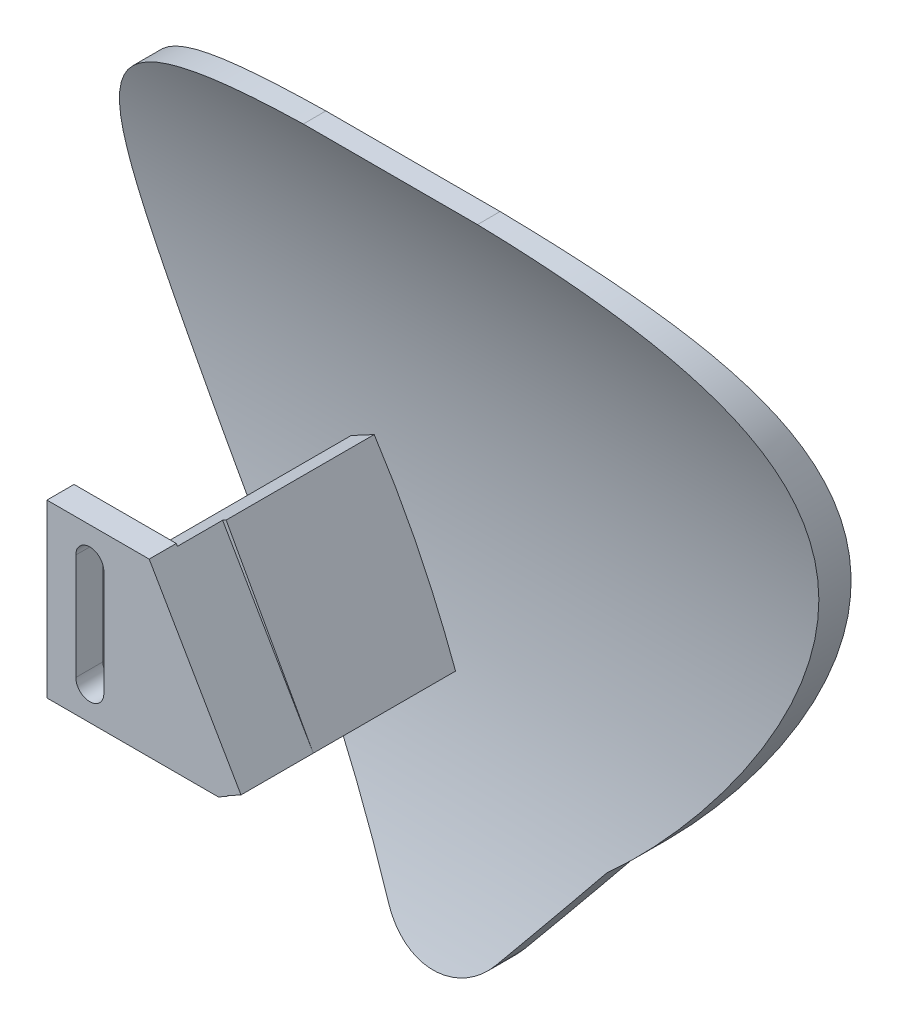
from build123d import *

# Parameters (mm, degrees)
SKETCH1_W               = 90
SKETCH1_H               = 90
BOSS_EXTRUDE1_DEPTH     = 20
CUT_EXTRUDE1_DEPTH      = 67.708320321
CUT_EXTRUDE1_DEPTH_BACK = 67.708320321
CUT_EXTRUDE2_DEPTH      = 67.708320486
CUT_EXTRUDE2_DEPTH_BACK = 67.708320486
CUT_EXTRUDE13_DEPTH     = 10
BOSS_EXTRUDE5_START     = 6.5
BOSS_EXTRUDE5_DEPTH     = 26.5
BOSS_EXTRUDE7_START     = -25
SKETCH26_W              = 3
SKETCH26_H              = 18.966666926
BOSS_EXTRUDE7_DEPTH     = 20
CUT_EXTRUDE23_START     = 25
SKETCH28_R              = 1.55
CUT_EXTRUDE23_DEPTH     = 10
CUT_EXTRUDE24_START     = 35
CUT_EXTRUDE24_DEPTH     = 10


with BuildPart() as part:
    # Sketch1 → Boss-Extrude1 (new body)
    with BuildSketch(Plane.XY):
        Rectangle(SKETCH1_W, SKETCH1_H)
    extrude(amount=BOSS_EXTRUDE1_DEPTH)

    # Sketch2 → Cut-Extrude1 (cut, two sides)
    with BuildSketch(Plane(origin=(0, 0, 0), x_dir=(0, 0, -1), z_dir=(1, 0, 0))) as cut_extrude1_sk:
        with BuildLine():
            Line((0, -45), (0, 45))
            Line((0, 45), (-17.5, 45))
            add(Edge.make_bspline(
                [(-17.5, 45), (1.11526928, 18.330109849), (-2.773030501, -17.812088562), (-17.5, -45)],
                knots=[0, 0, 0, 0, 1, 1, 1, 1], degree=3))
            Line((-17.5, -45), (0, -45))
        make_face()
        with BuildLine():
            add(Edge.make_bspline(
                [(-20, 45), (3.100953483, 4.754137608), (-20, -45)],
                knots=[0, 0, 0, 1, 1, 1], degree=2))
            Line((-20, -45), (-20, 45))
        make_face()
    extrude(amount=CUT_EXTRUDE1_DEPTH, mode=Mode.SUBTRACT)
    extrude(cut_extrude1_sk.sketch, amount=-CUT_EXTRUDE1_DEPTH_BACK, mode=Mode.SUBTRACT)

    # Sketch3 → Cut-Extrude2 (cut, two sides)
    with BuildSketch(Plane.XY) as cut_extrude2_sk:
        with BuildLine():
            ThreePointArc((5.952933229, -30.681551854), (0, -33.619470534), (-5.952933229, -30.681551854))
            Line((-5.952933229, -30.681551854), (-14.882333073, -19.02982596))
            add(Edge.make_bspline(
                [(-14.882333073, -19.02982596), (-33.37703632, -2.819308001), (-57.954503959, 42.329469412), (-9.638427065, 45)],
                knots=[0, 0, 0, 0, 0.942687649, 0.942687649, 0.942687649, 0.942687649], degree=3))
            Line((-9.638427065, 45), (-45, 45))
            Line((-45, 45), (-45, -45))
            Line((-45, -45), (45, -45))
            Line((45, -45), (45, 45))
            Line((45, 45), (9.638427065, 45))
            add(Edge.make_bspline(
                [(14.882333073, -19.02982596), (33.37703632, -2.819308001), (57.954503959, 42.329469412), (9.638427065, 45)],
                knots=[0, 0, 0, 0, 0.942687649, 0.942687649, 0.942687649, 0.942687649], degree=3))
            Line((14.882333073, -19.02982596), (5.952933229, -30.681551854))
        make_face()
    extrude(amount=CUT_EXTRUDE2_DEPTH, mode=Mode.SUBTRACT)
    extrude(cut_extrude2_sk.sketch, amount=-CUT_EXTRUDE2_DEPTH_BACK, mode=Mode.SUBTRACT)

    # Sketch15 → Cut-Extrude13 (cut)
    with BuildSketch(Plane(origin=(0, 0, 0), x_dir=(0, 0, -1), z_dir=(1, 0, 0))):
        Polygon((-6.544274822, -14.084003466), (-5.916371018, -10.261977823), (-5.185386391, -14.084003466), align=None)
    extrude(amount=CUT_EXTRUDE13_DEPTH, mode=Mode.SUBTRACT)

    # Sketch24 → Boss-Extrude5 (add)
    with BuildSketch(Plane.XY.offset(BOSS_EXTRUDE5_START)):
        Polygon((-15.802792048, 6.336123183), (-6.155905041, -11.183510692), (-3.52795996, -9.736477641), (-13.174846966, 7.783156234), align=None)
    extrude(amount=BOSS_EXTRUDE5_DEPTH)

    # Sketch26 → Boss-Extrude7 (add)
    with BuildSketch(Plane(origin=(0, 0, 0), x_dir=(0, 0, -1), z_dir=(1, 0, 0)).offset(BOSS_EXTRUDE7_START)):
        with Locations((-31.5, -1.700177229)):
            Rectangle(SKETCH26_W, SKETCH26_H)
    extrude(amount=BOSS_EXTRUDE7_DEPTH)

    # Sketch28 → Cut-Extrude23 (cut)
    with BuildSketch(Plane.XY.offset(CUT_EXTRUDE23_START)):
        with Locations((-20.256840538, 4.115140616)):
            Circle(SKETCH28_R)
        with BuildLine():
            Line((-18.706840538, -7.619333671), (-18.706840538, 4.115140616))
            ThreePointArc((-18.706840538, 4.115140616), (-20.256840538, 2.565140616), (-21.806840538, 4.115140616))
            Line((-21.806840538, 4.115140616), (-21.806840538, -7.619333671))
            ThreePointArc((-21.806840538, -7.619333671), (-20.256840538, -6.069333671), (-18.706840538, -7.619333671))
        make_face()
        with Locations((-20.256840538, -7.619333671)):
            Circle(SKETCH28_R)
    extrude(amount=CUT_EXTRUDE23_DEPTH, mode=Mode.SUBTRACT)

    # Sketch29 → Cut-Extrude24 (cut)
    with BuildSketch(Plane.XY.offset(CUT_EXTRUDE24_START)):
        Polygon((-3.77618872, 7.783156234), (-3.52795996, -9.736477641), (-13.688384135, 7.783156234), align=None)
        Polygon((-7.35673341, -11.956955683), (-3.65207434, -11.956955683), (-3.52795996, -9.736477641), align=None)
    extrude(amount=-CUT_EXTRUDE24_DEPTH, mode=Mode.SUBTRACT)


solid = part.part
